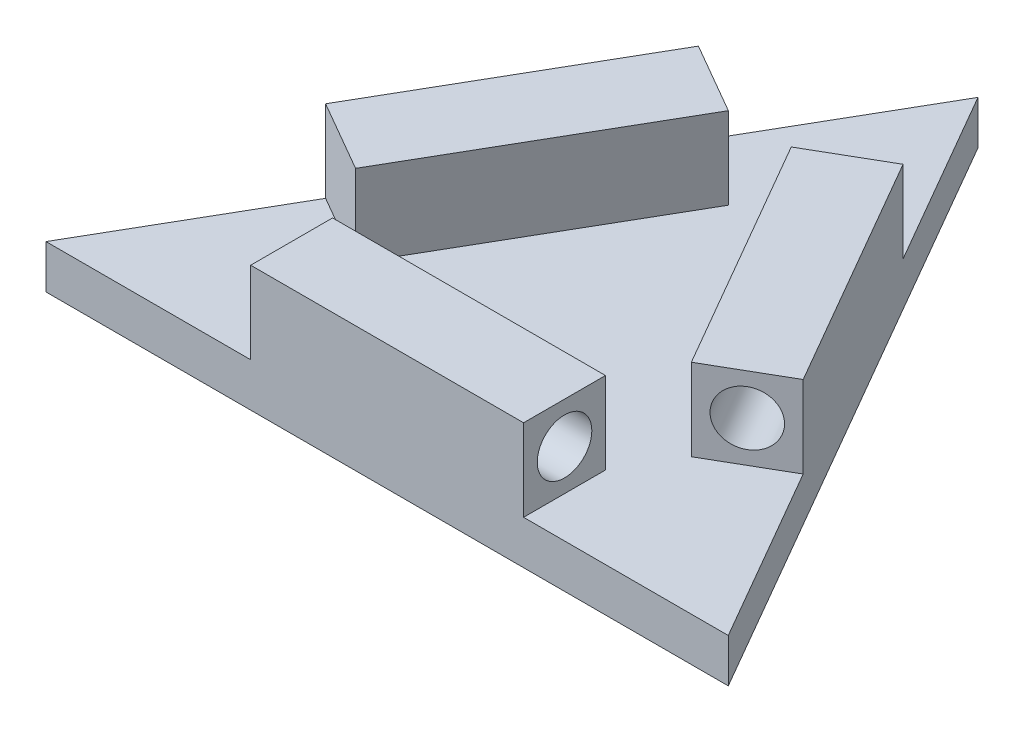
from build123d import *

# Parameters (mm, degrees)
BOSS_EXTRUDE1_DEPTH = 8
BOSS_EXTRUDE2_DEPTH = 15
SKETCH4_R           = 5
CUT_EXTRUDE1_DEPTH  = 40
SKETCH5_R           = 5
CUT_EXTRUDE2_DEPTH  = 40
SKETCH6_R           = 5
CUT_EXTRUDE3_DEPTH  = 40


with BuildPart() as part:
    # Sketch2 → Boss-Extrude1 (new body)
    with BuildSketch(Plane(origin=(0, 0, 0), x_dir=(1, 0, 0), z_dir=(0, 1, 0))):
        Polygon((-62.5, -54.126587737), (62.5, -54.126587737), (0, 54.126587737), align=None)
    extrude(amount=BOSS_EXTRUDE1_DEPTH)

    # Sketch3 → Boss-Extrude2 (add)
    with BuildSketch(Plane(origin=(0, 8, 0), x_dir=(1, 0, 0), z_dir=(0, 1, 0))):
        Polygon((31.25, 0), (18.75, 21.650635095), (5.759618943, 14.150635095), (30.759618943, -29.150635095), (43.75, -21.650635095), align=None)
        Polygon((0, -54.126587737), (25, -54.126587737), (25, -39.126587737), (-25, -39.126587737), (-25, -54.126587737), align=None)
        Polygon((-31.25, 0), (-43.75, -21.650635095), (-30.759618943, -29.150635095), (-5.759618943, 14.150635095), (-18.75, 21.650635095), align=None)
    extrude(amount=BOSS_EXTRUDE2_DEPTH)

    # Sketch4 → Cut-Extrude1 (cut)
    with BuildSketch(Plane(origin=(25, 0, 0), x_dir=(0, 0, -1), z_dir=(1, 0, 0))):
        with Locations((-46.626587737, 15.5)):
            Circle(SKETCH4_R)
    extrude(amount=-CUT_EXTRUDE1_DEPTH, mode=Mode.SUBTRACT)

    # Sketch5 → Cut-Extrude2 (cut)
    with BuildSketch(Plane(origin=(20.3125, 0, 35.182282029), x_dir=(0.866025404, 0, -0.5), z_dir=(0.5, 0, 0.866025404))):
        with Locations((19.563293868, 15.5)):
            Circle(SKETCH5_R)
    extrude(amount=-CUT_EXTRUDE2_DEPTH, mode=Mode.SUBTRACT)

    # Sketch6 → Cut-Extrude3 (cut)
    with BuildSketch(Plane(origin=(4.6875, 0, -8.11898816), x_dir=(-0.866025404, 0, -0.5), z_dir=(0.5, 0, -0.866025404))):
        with Locations((19.563293868, 15.5)):
            Circle(SKETCH6_R)
    extrude(amount=-CUT_EXTRUDE3_DEPTH, mode=Mode.SUBTRACT)


solid = part.part
